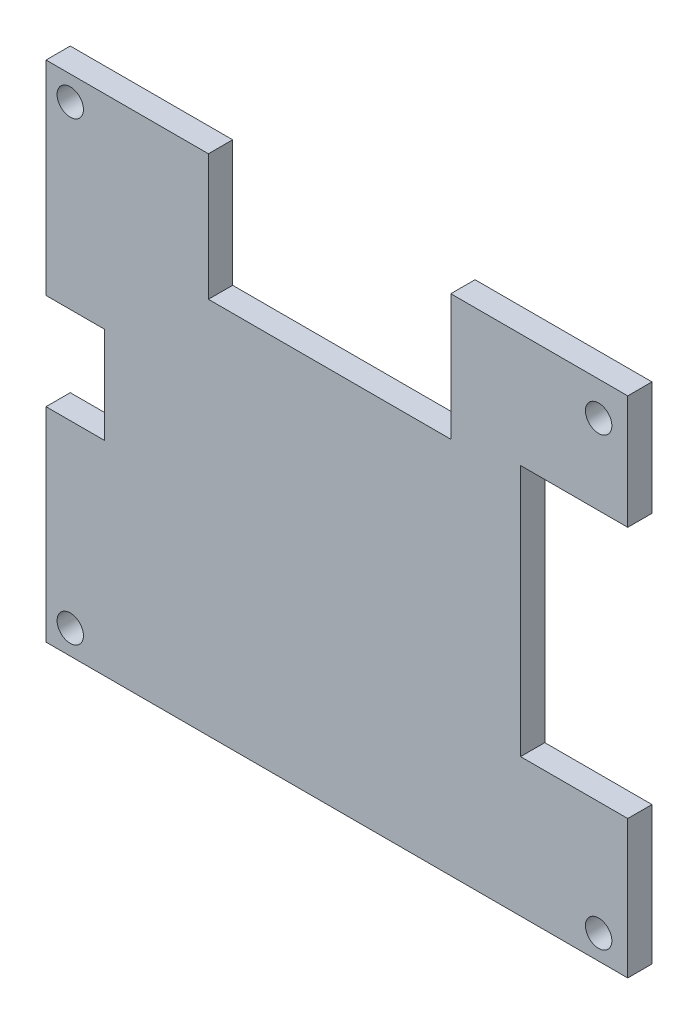
from build123d import *

# Parameters (mm, degrees)
BOSS_EXTRUDE1_DEPTH       = 3.175
F_4_CLEARANCE_HOLE1_D     = 3.4544
F_4_CLEARANCE_HOLE1_DEPTH = 10.16
F_4_CLEARANCE_HOLE1_TIP   = 1.037806461


with BuildPart() as part:
    # Sketch2 → Boss-Extrude1 (new body)
    with BuildSketch(Plane.XY):
        Polygon((-38.1, 33.02), (-16.8275, 33.02), (-16.8275, 16.51), (14.9225, 16.51), (14.9225, 33.02), (38.1, 33.02), (38.1, 18.1011502), (24.060772257, 18.1011502), (24.060772257, -14.926152342), (38.1, -14.926152342), (38.1, -33.02), (-38.1, -33.02), (-38.1, -6.305887107), (-30.445430268, -6.305887107), (-30.445430268, 6.305887107), (-38.1, 6.305887107), align=None)
    extrude(amount=BOSS_EXTRUDE1_DEPTH)

    # #4 Clearance Hole1
    with Locations(Plane.XY.offset(3.175)):
        with Locations((-34.925, 29.845), (34.29, 28.575), (-34.925, -29.845), (34.29, -29.845)):
            Hole(F_4_CLEARANCE_HOLE1_D / 2, depth=F_4_CLEARANCE_HOLE1_DEPTH)
            with Locations((0, 0, -(F_4_CLEARANCE_HOLE1_DEPTH + F_4_CLEARANCE_HOLE1_TIP / 2))):  # 118° drill point
                Cone(0, F_4_CLEARANCE_HOLE1_D / 2, F_4_CLEARANCE_HOLE1_TIP, mode=Mode.SUBTRACT)


solid = part.part
